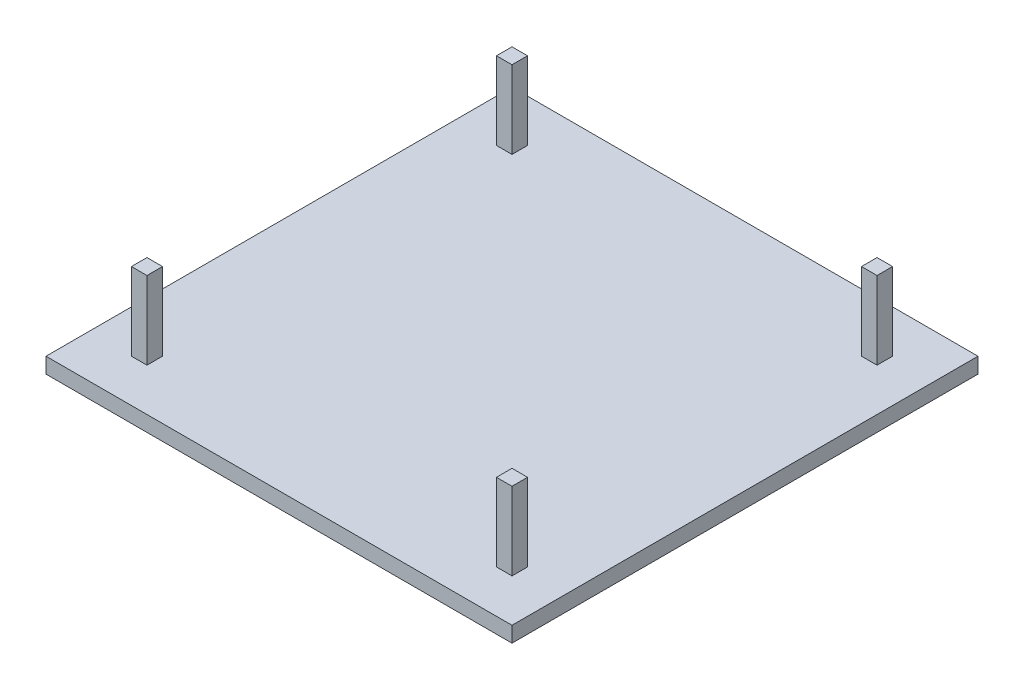
from build123d import *

# Parameters (mm, degrees)
SKETCH1_W           = 60
SKETCH1_H           = 60
BOSS_EXTRUDE1_DEPTH = 2
SKETCH2_W           = 2
SKETCH2_H           = 2
BOSS_EXTRUDE2_DEPTH = 10


with BuildPart() as part:
    # Sketch1 → Boss-Extrude1 (new body)
    with BuildSketch(Plane(origin=(0, 0, 0), x_dir=(1, 0, 0), z_dir=(0, 1, 0))):
        with Locations((4.932614555, -8.84097035)):
            Rectangle(SKETCH1_W, SKETCH1_H)
    extrude(amount=BOSS_EXTRUDE1_DEPTH)

    # Sketch2 → Boss-Extrude2 (add)
    with BuildSketch(Plane(origin=(0, 2, 0), x_dir=(1, 0, 0), z_dir=(0, 1, 0))):
        with Locations((-18.567385445, 14.65902965)):
            Rectangle(SKETCH2_W, SKETCH2_H)
        with Locations((28.432614555, 14.65902965)):
            Rectangle(SKETCH2_W, SKETCH2_H)
        with Locations((28.432614555, -32.34097035)):
            Rectangle(SKETCH2_W, SKETCH2_H)
        with Locations((-18.567385445, -32.34097035)):
            Rectangle(SKETCH2_W, SKETCH2_H)
    extrude(amount=BOSS_EXTRUDE2_DEPTH)


solid = part.part
